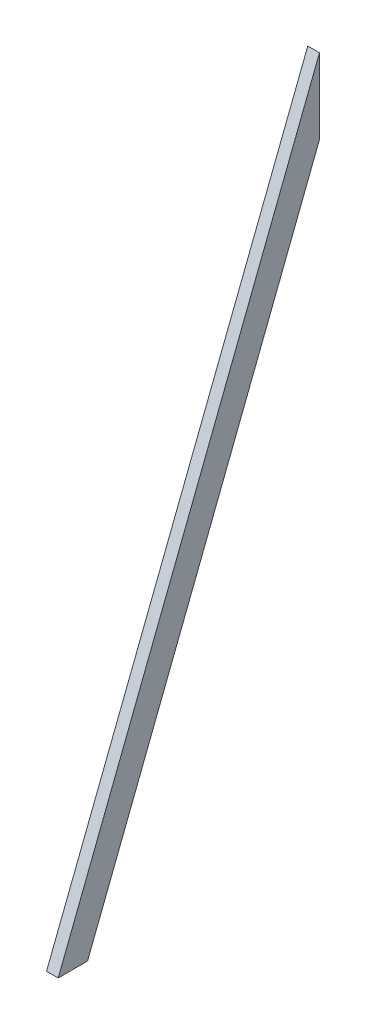
from build123d import *

# Parameters (mm, degrees)
BOSS_EXTRUDE1_DEPTH = 38.1


with BuildPart() as part:
    # Sketch1 → Boss-Extrude1 (new body)
    with BuildSketch(Plane(origin=(0, 0, 0), x_dir=(0, 0, -1), z_dir=(1, 0, 0))):
        Polygon((-425.45, -1092.2), (-330.043382097, -1092.2), (425.45, 847.27554807), (425.45, 1092.2), align=None)
    extrude(amount=BOSS_EXTRUDE1_DEPTH)


solid = part.part
